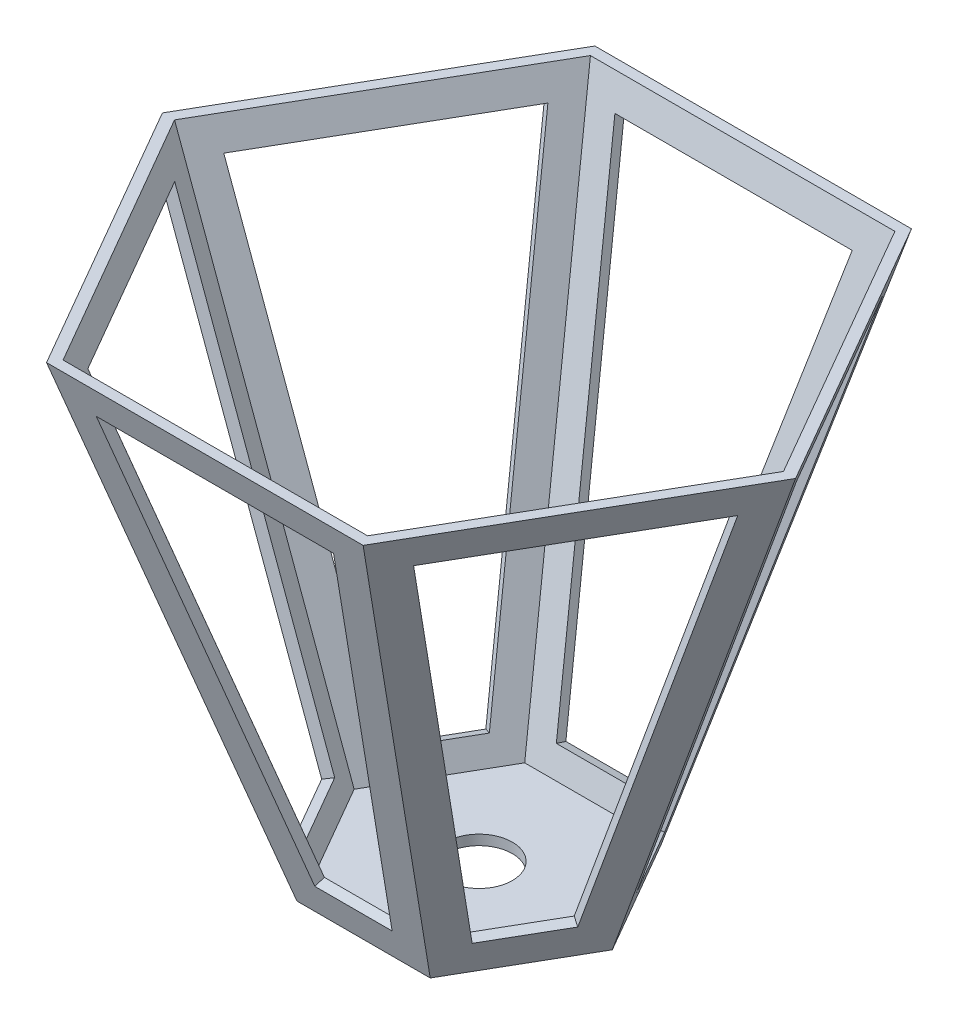
from build123d import *

# Parameters (mm, degrees)
VACIADO1_T            = -3
CORTAR_EXTRUIR1_DEPTH = 3
CORTAR_EXTRUIR2_REACH = 152
CROQUIS4_R            = 10
MATRIZC1_COUNT        = 6


with BuildPart() as part:
    # Croquis2 → Recubrir1 section 0
    with BuildSketch(Plane(origin=(0, 150, 0), x_dir=(-1, 0, 0), z_dir=(0, 1, 0))):
        Polygon((-95, 0), (-47.5, -82.27241336), (47.5, -82.27241336), (95, 0), (47.5, 82.27241336), (-47.5, 82.27241336), align=None)
    # Croquis1 → Recubrir1 section 1
    with BuildSketch(Plane(origin=(0, 0, 0), x_dir=(1, 0, 0), z_dir=(0, 1, 0))):
        Polygon((-40, 0), (-20, -34.641016151), (20, -34.641016151), (40, 0), (20, 34.641016151), (-20, 34.641016151), align=None)
    loft()

    # Vaciado1
    vaciado1_openings = [part.faces().sort_by_distance(p)[0] for p in [
        (0, 150, 0),
    ]]
    offset(amount=VACIADO1_T, openings=vaciado1_openings, kind=Kind.INTERSECTION)

    # Croquis3 → Cortar-Extruir1 (cut)
    with BuildSketch(Plane(origin=(0, -9.992429977, 31.467993476), x_dir=(1, 0, 0), z_dir=(0, -0.302650417, 0.953101634))):
        Polygon((-11.595838701, 20.484117977), (11.595838701, 20.484117977), (35.601132708, 157.865025332), (-35.601132708, 157.865025332), align=None)
    cortar_extruir1 = extrude(amount=-CORTAR_EXTRUIR1_DEPTH, mode=Mode.SUBTRACT)

    # Croquis4 → Cortar-Extruir2 (cut, up to next)
    with BuildSketch(Plane.XZ, mode=Mode.PRIVATE) as cortar_extruir2_sk1:
        Circle(CROQUIS4_R)
    cortar_extruir2_tool1 = extrude(cortar_extruir2_sk1.sketch, amount=-CORTAR_EXTRUIR2_REACH, mode=Mode.PRIVATE) & part.part
    add(cortar_extruir2_tool1.solids().sort_by_distance((0, 0, 0))[0], mode=Mode.SUBTRACT)

    # MatrizC1: Cortar-Extruir1 ×6 about axis
    matrizc1_axis = Axis((0, 0, 0), (0, 1, 0))
    for i in range(1, MATRIZC1_COUNT):
        add(cortar_extruir1.rotate(matrizc1_axis, i * 360 / MATRIZC1_COUNT), mode=Mode.SUBTRACT)


solid = part.part
